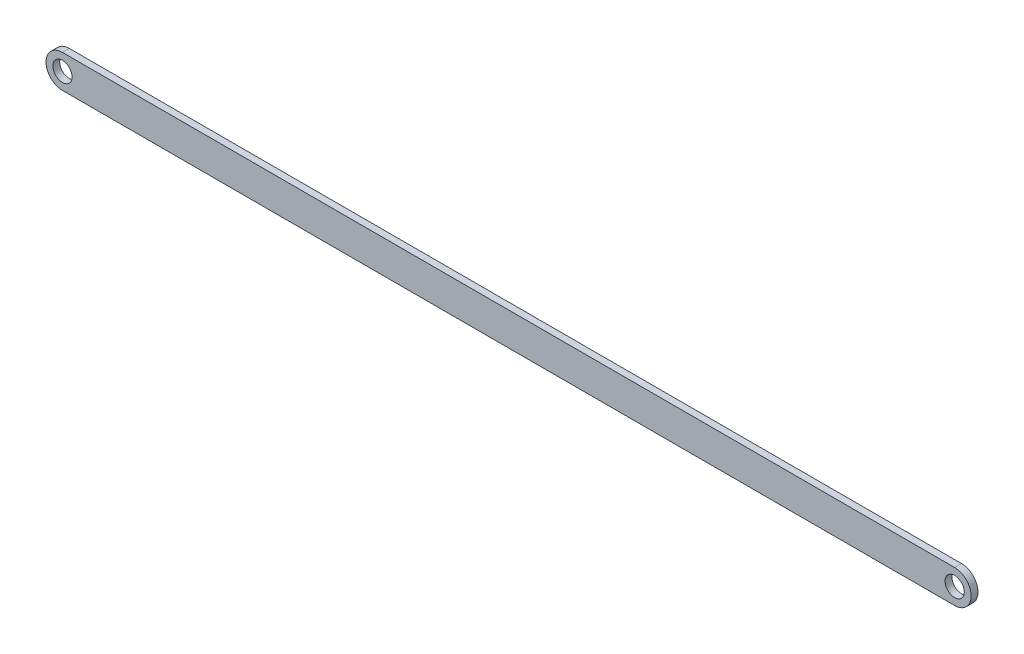
from build123d import *

# Parameters (mm, degrees)
DODANIE_WYCI_GNI_CIE1_DEPTH = 5
SZKIC2_R                    = 7
WYTNIJ_WYCI_GNI_CIE1_DEPTH  = 5


with BuildPart() as part:
    # Szkic1 → Dodanie-wyciągnięcie1 (new body)
    with BuildSketch(Plane.XY):
        with BuildLine():
            Line((0, 0), (650, 0))
            ThreePointArc((650, 0), (662, 12), (650, 24))
            Line((650, 24), (0, 24))
            ThreePointArc((0, 24), (-12, 12), (0, 0))
        make_face()
    extrude(amount=DODANIE_WYCI_GNI_CIE1_DEPTH)

    # Szkic2 → Wytnij-wyciągnięcie1 (cut)
    with BuildSketch(Plane.XY.offset(5)):
        with Locations((0, 12)):
            Circle(SZKIC2_R)
        with Locations((650, 12)):
            Circle(SZKIC2_R)
    extrude(amount=-WYTNIJ_WYCI_GNI_CIE1_DEPTH, mode=Mode.SUBTRACT)


solid = part.part
